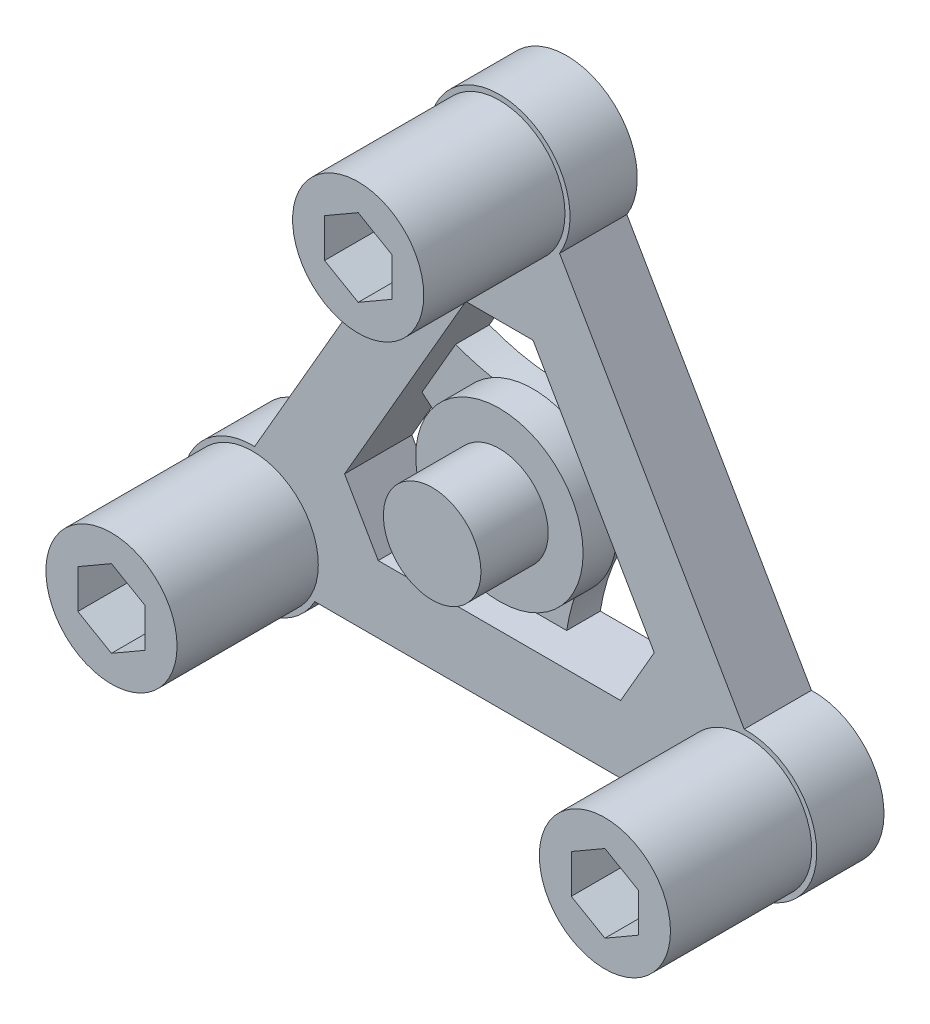
from build123d import *

# Parameters (mm, degrees)
BOSS_EXTRUDE1_DEPTH = 5
BOSS_EXTRUDE2_DEPTH = 5
SKETCH4_R           = 9.75
BOSS_EXTRUDE3_DEPTH = 21
SKETCH5_R           = 12.441578391
BOSS_EXTRUDE4_DEPTH = 5
SKETCH5_3_R         = 7.25
BOSS_EXTRUDE5_DEPTH = 15
CHAMFER1_SIZE       = 10
CUT_EXTRUDE1_DEPTH  = 10


with BuildPart() as part:
    # Sketch2 → Boss-Extrude1 (new body, symmetric)
    with BuildSketch(Plane.XY):
        with BuildLine():
            ThreePointArc((8.946673347, 36.860907204), (0, 52.857), (-8.946673347, 36.860907204))
            Line((-8.946673347, 36.860907204), (-36.395818719, -10.682407204))
            ThreePointArc((-36.395818719, -10.682407204), (-45.775504768, -26.4285), (-27.449145372, -26.1785))
            Line((-27.449145372, -26.1785), (27.449145372, -26.1785))
            ThreePointArc((27.449145372, -26.1785), (45.775504768, -26.4285), (36.395818719, -10.682407204))
            Line((36.395818719, -10.682407204), (8.946673347, 36.860907204))
        make_face()
        Polygon((-28.02198399, -16.1785), (0, 32.357), (28.02198399, -16.1785), align=None, mode=Mode.SUBTRACT)
    extrude(amount=BOSS_EXTRUDE1_DEPTH, both=True)

    # Sketch3 → Boss-Extrude2 (add)
    with BuildSketch(Plane.XY):
        with BuildLine():
            Line((-16.510991995, 3.759122981), (-11.510991995, 12.419377019))
            ThreePointArc((-11.510991995, 12.419377019), (0, 10.282645658), (11.510991995, 12.419377019))
            Line((11.510991995, 12.419377019), (16.510991995, 3.759122981))
            ThreePointArc((16.510991995, 3.759122981), (8.905032358, -5.141322829), (5, -16.1785))
            Line((5, -16.1785), (-5, -16.1785))
            ThreePointArc((-5, -16.1785), (-8.905032358, -5.141322829), (-16.510991995, 3.759122981))
        make_face()
    extrude(amount=-BOSS_EXTRUDE2_DEPTH)

    # Sketch4 → Boss-Extrude3 (add)
    with BuildSketch(Plane.XY.offset(5)):
        with Locations((-36.682238028, -21.1785)):
            Circle(SKETCH4_R)
        with Locations((36.682238028, -21.1785)):
            Circle(SKETCH4_R)
        with Locations((0, 42.357)):
            Circle(SKETCH4_R)
    extrude(amount=BOSS_EXTRUDE3_DEPTH)

    # Sketch5 → Boss-Extrude4 (add)
    with BuildSketch(Plane.XY):
        Circle(SKETCH5_R)
    extrude(amount=BOSS_EXTRUDE4_DEPTH)

    # Sketch5_3 → Boss-Extrude5 (add)
    with BuildSketch(Plane.XY):
        Circle(SKETCH5_3_R)
    extrude(amount=BOSS_EXTRUDE5_DEPTH)

    # Chamfer1
    chamfer1_edges = [part.edges().sort_by_distance(p)[0] for p in [
        (28.02198399, -16.1785, 0),
        (-28.02198399, -16.1785, 0),
        (0, 32.357, 0),
    ]]
    chamfer(chamfer1_edges, length=CHAMFER1_SIZE)

    # Sketch8 → Cut-Extrude1 (cut)
    with BuildSketch(Plane.XY.offset(26)):
        Polygon((-41.682238028, -24.065251346), (-36.682238028, -26.952002692), (-31.682238028, -24.065251346), (-31.682238028, -18.291748654), (-36.682238028, -15.404997308), (-41.682238028, -18.291748654), align=None)
        Polygon((41.682238028, -24.065251346), (41.682238028, -18.291748654), (36.682238028, -15.404997308), (31.682238028, -18.291748654), (31.682238028, -24.065251346), (36.682238028, -26.952002692), align=None)
        Polygon((0, 48.130502692), (-5, 45.243751346), (-5, 39.470248654), (0, 36.583497308), (5, 39.470248654), (5, 45.243751346), align=None)
    extrude(amount=-CUT_EXTRUDE1_DEPTH, mode=Mode.SUBTRACT)


solid = part.part
